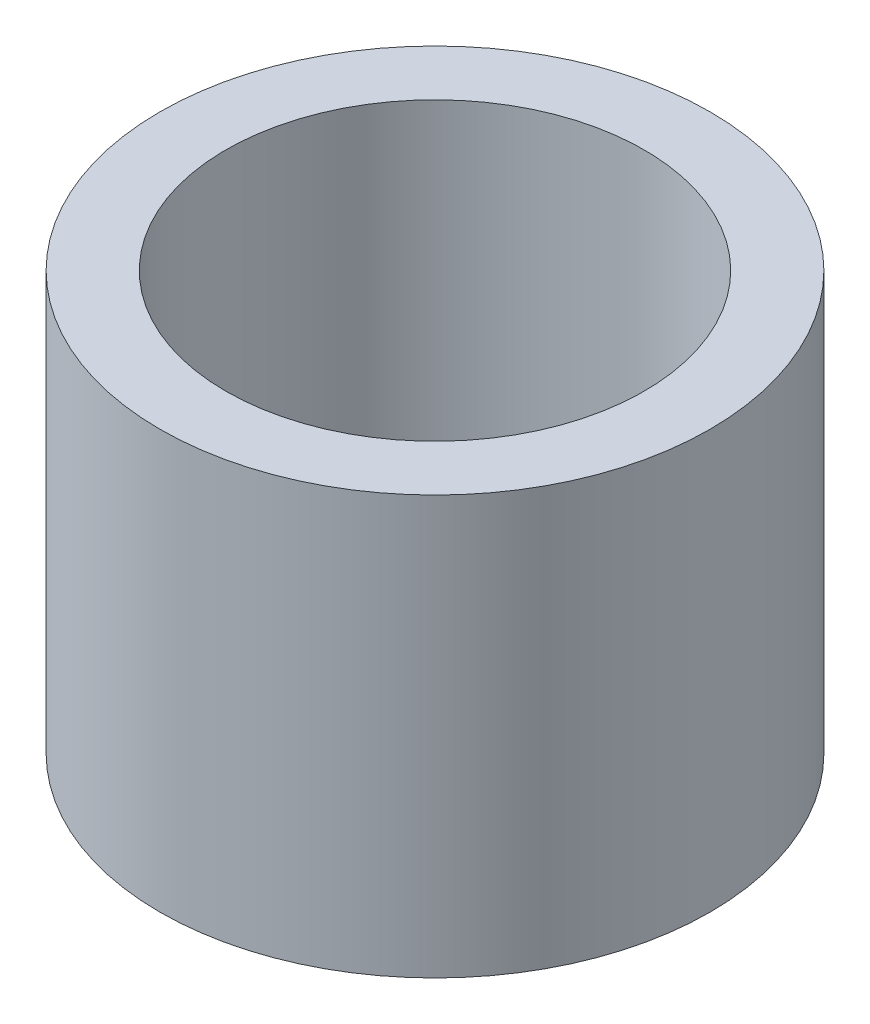
from build123d import *

# Parameters (mm, degrees)
SKETCH1_R           = 16.7005
SKETCH1_R_2         = 12.7
BOSS_EXTRUDE1_DEPTH = 25.4


with BuildPart() as part:
    # Sketch1 → Boss-Extrude1 (new body)
    with BuildSketch(Plane(origin=(0, 0, 0), x_dir=(1, 0, 0), z_dir=(0, 1, 0))):
        Circle(SKETCH1_R)
        Circle(SKETCH1_R_2, mode=Mode.SUBTRACT)
    extrude(amount=BOSS_EXTRUDE1_DEPTH)


solid = part.part
